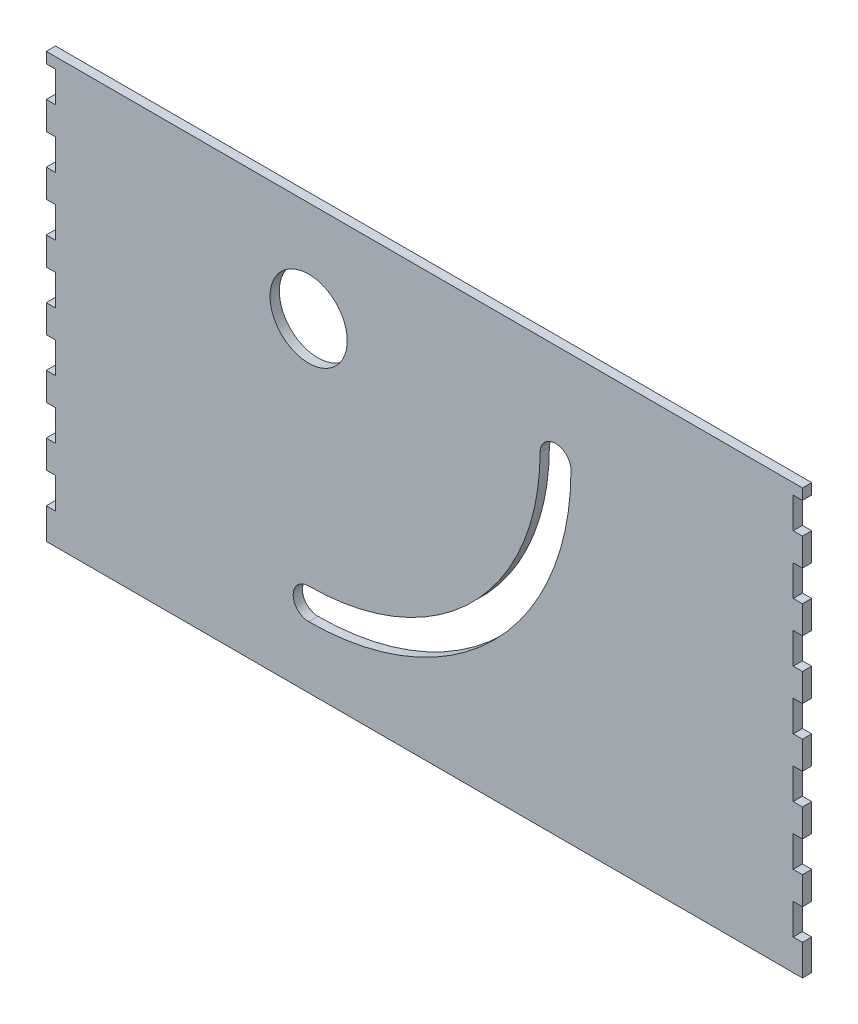
from build123d import *

# Parameters (mm, degrees)
SKETCH1_R           = 12.5
BOSS_EXTRUDE1_DEPTH = 3


with BuildPart() as part:
    # Sketch1 → Boss-Extrude1 (new body)
    with BuildSketch(Plane.XY):
        Polygon((244.5, 137.5), (244.5, 134), (241.5, 134), (241.5, 124), (244.5, 124), (244.5, 115), (241.5, 115), (241.5, 105), (244.5, 105), (244.5, 96), (241.5, 96), (241.5, 86), (244.5, 86), (244.5, 77), (241.5, 77), (241.5, 67), (244.5, 67), (244.5, 58), (241.5, 58), (241.5, 48), (244.5, 48), (244.5, 39), (241.5, 39), (241.5, 29), (244.5, 29), (244.5, 20), (241.5, 20), (241.5, 10), (244.5, 10), (244.5, 0), (-0.5, 0), (-0.5, 10), (2.5, 10), (2.5, 20), (-0.5, 20), (-0.5, 29), (2.5, 29), (2.5, 39), (-0.5, 39), (-0.5, 48), (2.5, 48), (2.5, 58), (-0.5, 58), (-0.5, 67), (2.5, 67), (2.5, 77), (-0.5, 77), (-0.5, 86), (2.5, 86), (2.5, 96), (-0.5, 96), (-0.5, 105), (2.5, 105), (2.5, 115), (-0.5, 115), (-0.5, 124), (2.5, 124), (2.5, 134), (-0.5, 134), (-0.5, 137.5), align=None)
        with Locations((84.5, 105)):
            Circle(SKETCH1_R, mode=Mode.SUBTRACT)
        with BuildLine():
            ThreePointArc((169.5, 105), (164.5, 110), (159.5, 105))
            ThreePointArc((159.5, 105), (137.533008589, 51.966991411), (84.5, 30))
            ThreePointArc((84.5, 30), (79.5, 25), (84.5, 20))
            ThreePointArc((84.5, 20), (144.604076401, 44.895923599), (169.5, 105))
        make_face(mode=Mode.SUBTRACT)
    extrude(amount=BOSS_EXTRUDE1_DEPTH)


solid = part.part
